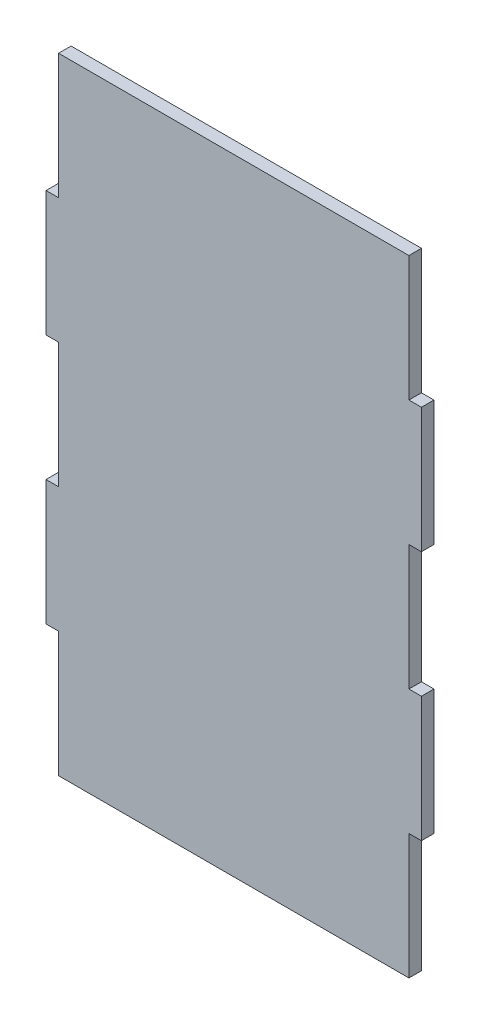
from build123d import *

# Parameters (mm, degrees)
SKETCH1_W           = 76.2
SKETCH1_H           = 127
BOSS_EXTRUDE1_DEPTH = 2.54
SKETCH2_W           = 2.54
SKETCH2_H           = 25.4
CUT_EXTRUDE1_DEPTH  = 3.54
SKETCH4_W           = 2.54
SKETCH4_H           = 25.4
CUT_EXTRUDE3_DEPTH  = 3.54
SKETCH3_W           = 2.54
SKETCH3_H           = 25.4
CUT_EXTRUDE4_DEPTH  = 3.54


with BuildPart() as part:
    # Sketch1 → Boss-Extrude1 (new body)
    with BuildSketch(Plane.XY):
        with Locations((38.1, 63.5)):
            Rectangle(SKETCH1_W, SKETCH1_H)
    extrude(amount=BOSS_EXTRUDE1_DEPTH)

    # Sketch2 → Cut-Extrude1 (cut, through all)
    with BuildSketch(Plane.XY.offset(2.54)):
        with Locations((1.27, 114.3)):
            Rectangle(SKETCH2_W, SKETCH2_H)
    extrude(amount=-CUT_EXTRUDE1_DEPTH, mode=Mode.SUBTRACT)

    # Sketch4 → Cut-Extrude3 (cut, through all)
    with BuildSketch(Plane.XY.offset(2.54)):
        with Locations((1.27, 12.7)):
            Rectangle(SKETCH4_W, SKETCH4_H)
        with Locations((74.93, 12.7)):
            Rectangle(SKETCH4_W, SKETCH4_H)
        with Locations((1.27, 63.5)):
            Rectangle(SKETCH4_W, SKETCH4_H)
        with Locations((74.93, 63.5)):
            Rectangle(SKETCH4_W, SKETCH4_H)
    extrude(amount=-CUT_EXTRUDE3_DEPTH, mode=Mode.SUBTRACT)

    # Sketch3 → Cut-Extrude4 (cut, through all)
    with BuildSketch(Plane.XY.offset(2.54)):
        with Locations((74.93, 114.3)):
            Rectangle(SKETCH3_W, SKETCH3_H)
    extrude(amount=-CUT_EXTRUDE4_DEPTH, mode=Mode.SUBTRACT)


solid = part.part
